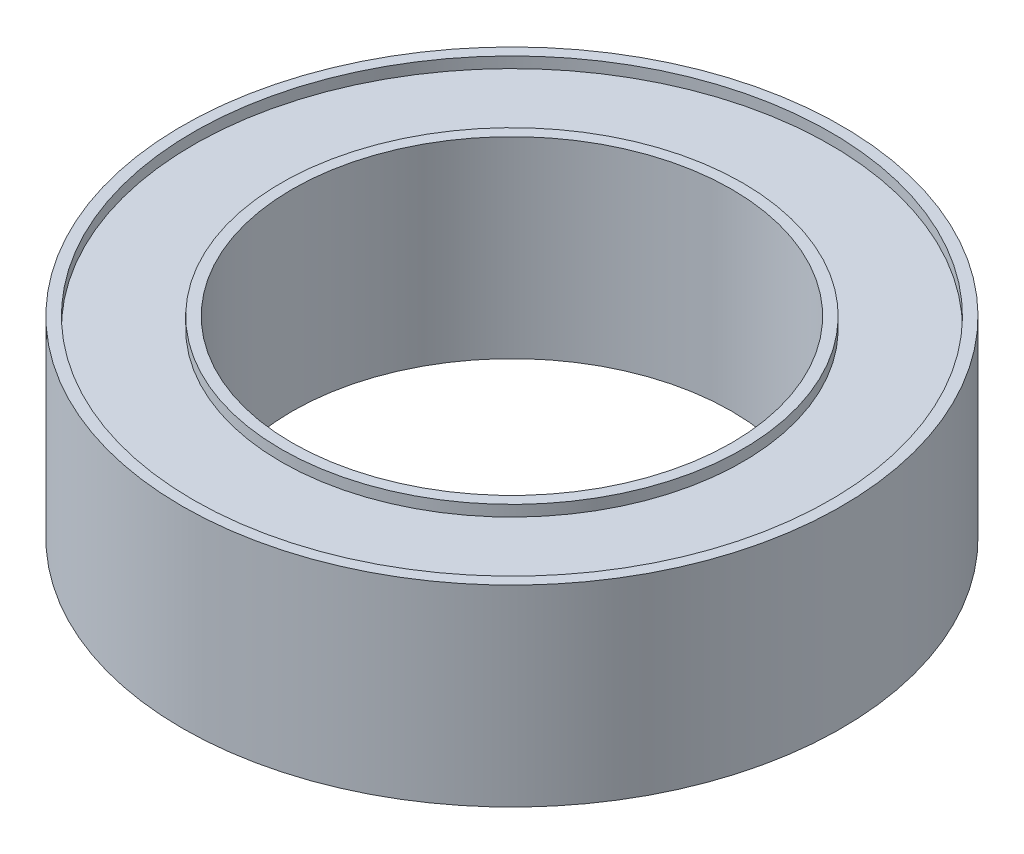
from build123d import *

# Parameters (mm, degrees)
SKETCH1_R           = 6
SKETCH1_R_2         = 4
BOSS_EXTRUDE1_DEPTH = 1.75
SKETCH2_R           = 5.8
SKETCH2_R_2         = 4.2
CUT_EXTRUDE1_DEPTH  = 0.2


with BuildPart() as part:
    # Sketch1 → Boss-Extrude1 (new body, symmetric)
    with BuildSketch(Plane(origin=(0, 0, 0), x_dir=(1, 0, 0), z_dir=(0, 1, 0))):
        Circle(SKETCH1_R)
        Circle(SKETCH1_R_2, mode=Mode.SUBTRACT)
    extrude(amount=BOSS_EXTRUDE1_DEPTH, both=True)

    # Sketch2 → Cut-Extrude1 (cut)
    with BuildSketch(Plane(origin=(0, 1.75, 0), x_dir=(1, 0, 0), z_dir=(0, 1, 0))):
        Circle(SKETCH2_R)
        Circle(SKETCH2_R_2, mode=Mode.SUBTRACT)
    cut_extrude1 = extrude(amount=-CUT_EXTRUDE1_DEPTH, mode=Mode.SUBTRACT)

    # Mirror2: Cut-Extrude1 across plane
    add(cut_extrude1.mirror(Plane.ZX), mode=Mode.SUBTRACT)


solid = part.part
